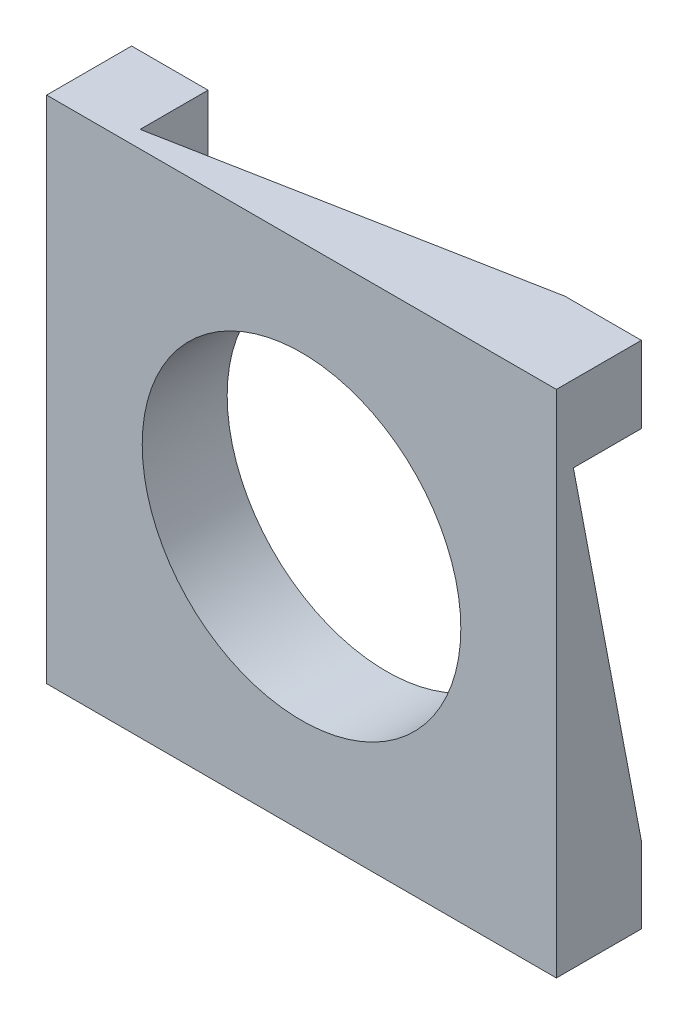
from build123d import *

# Parameters (mm, degrees)
CROQUIS1_W              = 600
CROQUIS1_H              = 600
CROQUIS1_R              = 187.5
SALIENTE_EXTRUIR1_DEPTH = 100
CORTAR_EXTRUIR6_DEPTH   = 80
CORTAR_EXTRUIR7_DEPTH   = 80
CORTAR_EXTRUIR8_DEPTH   = 80
CORTAR_EXTRUIR9_DEPTH   = 80


with BuildPart() as part:
    # Croquis1 → Saliente-Extruir1 (new body)
    with BuildSketch(Plane.XY):
        with Locations((24.047372846, 17.859468054)):
            Rectangle(CROQUIS1_W, CROQUIS1_H)
        with Locations((24.047372846, 17.859468054)):
            Circle(CROQUIS1_R, mode=Mode.SUBTRACT)
    extrude(amount=SALIENTE_EXTRUIR1_DEPTH)

    # Croquis2 → Cortar-Extruir6 (cut)
    with BuildSketch(Plane.ZY.offset(275.952627154)):
        Polygon((80, -192.140531946), (0, 227.859468054), (0, -192.140531946), align=None)
    extrude(amount=-CORTAR_EXTRUIR6_DEPTH, mode=Mode.SUBTRACT)

    # Croquis3 → Cortar-Extruir7 (cut)
    with BuildSketch(Plane.XZ.offset(282.140531946)):
        Polygon((234.047372846, 80), (-185.952627154, 0), (234.047372846, 0), align=None)
    extrude(amount=-CORTAR_EXTRUIR7_DEPTH, mode=Mode.SUBTRACT)

    # Croquis4 → Cortar-Extruir8 (cut)
    with BuildSketch(Plane(origin=(324.047372846, 0, 0), x_dir=(0, 0, -1), z_dir=(1, 0, 0))):
        Polygon((-80, 227.859468054), (0, -192.140531946), (0, 227.859468054), align=None)
    extrude(amount=-CORTAR_EXTRUIR8_DEPTH, mode=Mode.SUBTRACT)

    # Croquis6 → Cortar-Extruir9 (cut)
    with BuildSketch(Plane(origin=(0, 317.859468054, 0), x_dir=(1, 0, 0), z_dir=(0, 1, 0))):
        Polygon((234.047372846, 0), (-185.952627154, 0), (-185.952627154, -80), align=None)
    extrude(amount=-CORTAR_EXTRUIR9_DEPTH, mode=Mode.SUBTRACT)


solid = part.part
